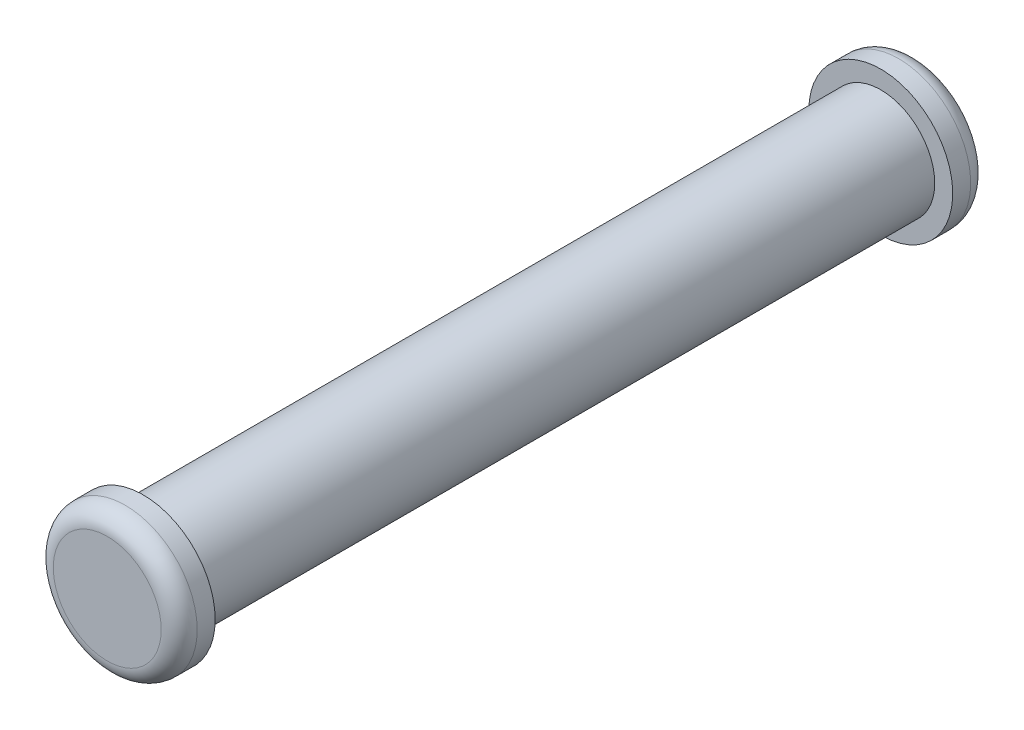
from build123d import *

# Parameters (mm, degrees)
SKETCH1_R           = 1.5
BOSS_EXTRUDE1_DEPTH = 20.5
SKETCH2_R           = 2
BOSS_EXTRUDE2_DEPTH = 1
SKETCH3_R           = 2
BOSS_EXTRUDE3_DEPTH = 1
FILLET1_R           = 0.5


with BuildPart() as part:
    # Sketch1 → Boss-Extrude1 (new body)
    with BuildSketch(Plane.XY):
        Circle(SKETCH1_R)
    extrude(amount=BOSS_EXTRUDE1_DEPTH)

    # Sketch2 → Boss-Extrude2 (add)
    with BuildSketch(Plane(origin=(0, 0, 0), x_dir=(-1, 0, 0), z_dir=(0, 0, -1))):
        Circle(SKETCH2_R)
    extrude(amount=BOSS_EXTRUDE2_DEPTH)

    # Sketch3 → Boss-Extrude3 (add)
    with BuildSketch(Plane.XY.offset(20.5)):
        Circle(SKETCH3_R)
    extrude(amount=BOSS_EXTRUDE3_DEPTH)

    # Fillet1
    fillet1_edges = [part.edges().sort_by_distance(p)[0] for p in [
        (-2, 0, 21.5),
        (2, 0, -1),
    ]]
    fillet(fillet1_edges, radius=FILLET1_R)


solid = part.part
